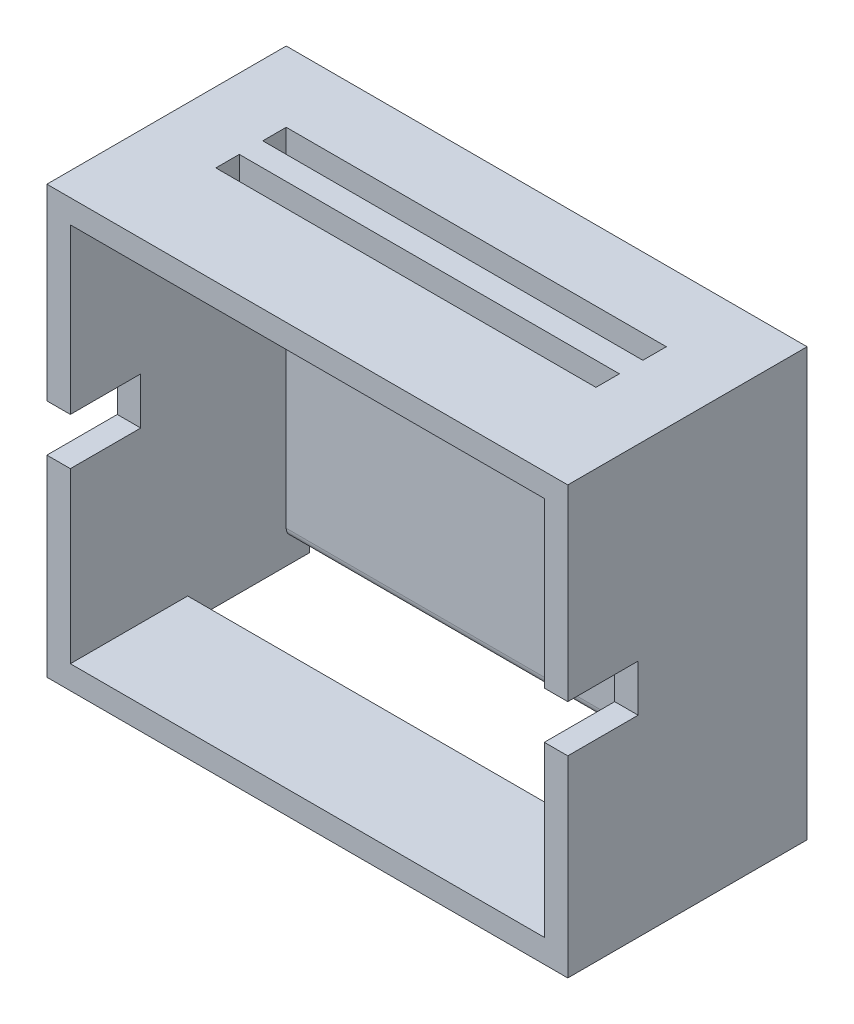
from build123d import *

# Parameters (mm, degrees)
SKETCH_1_W          = 111
SKETCH_1_H          = 91
SKETCH_1_W_2        = 101
SKETCH_1_H_2        = 81
EXTRUDE_1_DEPTH     = 46
SKETCH_2_W          = 111
SKETCH_2_H          = 91
EXTRUDE_2_DEPTH     = 5
SKETCH_3_W          = 101
SKETCH_3_H          = 26
CUT_EXTRUDE_1_DEPTH = 5
FILLET_1_R          = 2
SKETCH_4_W          = 5
SKETCH_4_H          = 10
CUT_EXTRUDE_2_DEPTH = 15
SKETCH_5_W          = 81
SKETCH_5_H          = 5
CUT_EXTRUDE_3_DEPTH = 5


with BuildPart() as part:
    # 草圖1 → 填料-伸長1 (new body)
    with BuildSketch(Plane.XY):
        with Locations((18.39111128, 6.255540432)):
            Rectangle(SKETCH_1_W, SKETCH_1_H)
        with Locations((18.39111128, 6.255540432)):
            Rectangle(SKETCH_1_W_2, SKETCH_1_H_2, mode=Mode.SUBTRACT)
    extrude(amount=EXTRUDE_1_DEPTH)

    # 草圖2 → 填料-伸長2 (add)
    with BuildSketch(Plane(origin=(0, 0, 0), x_dir=(-1, 0, 0), z_dir=(0, 0, -1))):
        with Locations((-18.39111128, 6.255540432)):
            Rectangle(SKETCH_2_W, SKETCH_2_H)
    extrude(amount=EXTRUDE_2_DEPTH)

    # 草圖3 → 除料-伸長1 (cut)
    with BuildSketch(Plane.XZ.offset(39.244459568)):
        with Locations((18.39111128, 8)):
            Rectangle(SKETCH_3_W, SKETCH_3_H)
    extrude(amount=-CUT_EXTRUDE_1_DEPTH, mode=Mode.SUBTRACT)

    # 圓角1
    fillet_1_edges = [part.edges().sort_by_distance(p)[0] for p in [
        (18.39111128, -34.244459568, 0),
    ]]
    fillet(fillet_1_edges, radius=FILLET_1_R)

    # 草圖4 → 除料-伸長2 (cut)
    with BuildSketch(Plane.XY.offset(46)):
        with Locations((-34.60888872, 6.755540432)):
            Rectangle(SKETCH_4_W, SKETCH_4_H)
        with Locations((71.39111128, 6.755540432)):
            Rectangle(SKETCH_4_W, SKETCH_4_H)
    extrude(amount=-CUT_EXTRUDE_2_DEPTH, mode=Mode.SUBTRACT)

    # 草圖5 → 除料-伸長3 (cut)
    with BuildSketch(Plane(origin=(0, 51.755540432, 0), x_dir=(1, 0, 0), z_dir=(0, 1, 0))):
        with Locations((18.39111128, -22.5)):
            Rectangle(SKETCH_5_W, SKETCH_5_H)
        with Locations((18.39111128, -12.5)):
            Rectangle(SKETCH_5_W, SKETCH_5_H)
    extrude(amount=-CUT_EXTRUDE_3_DEPTH, mode=Mode.SUBTRACT)


solid = part.part
